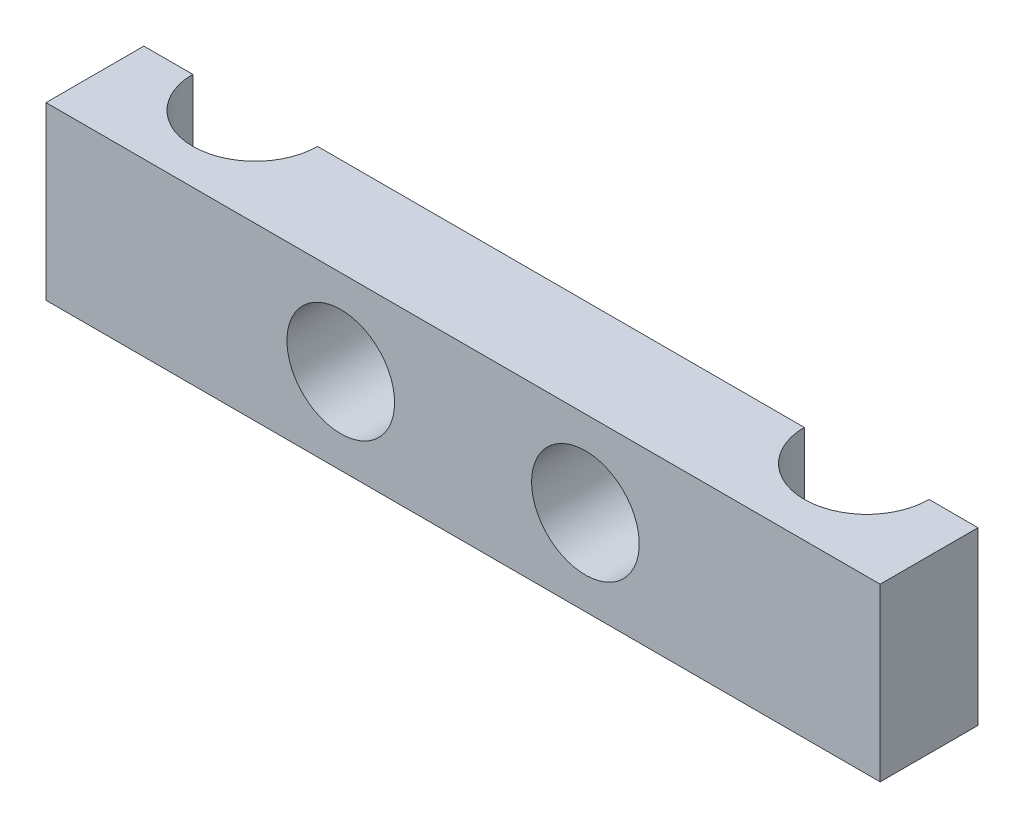
from build123d import *

# Parameters (mm, degrees)
BOSS_EXTRUDE1_DEPTH = 7
SKETCH2_R           = 2.2
CUT_EXTRUDE1_DEPTH  = 4


with BuildPart() as part:
    # Sketch1 → Boss-Extrude1 (new body)
    with BuildSketch(Plane(origin=(0, 0, 0), x_dir=(1, 0, 0), z_dir=(0, 1, 0))):
        with BuildLine():
            Line((0, 0), (-17.05, 0))
            Line((-17.05, 0), (-17.05, 4))
            Line((-17.05, 4), (-15.05, 4))
            ThreePointArc((-15.05, 4), (-12.5, 1.45), (-9.95, 4))
            Line((-9.95, 4), (0, 4))
            Line((0, 4), (0, 0))
        make_face()
    extrude(amount=BOSS_EXTRUDE1_DEPTH)

    # Sketch2 → Cut-Extrude1 (cut)
    with BuildSketch(Plane.XY):
        with Locations((-5, 3.5)):
            Circle(SKETCH2_R)
    extrude(amount=-CUT_EXTRUDE1_DEPTH, mode=Mode.SUBTRACT)

    # Mirror1: part across plane


with BuildPart() as part_1:
    add(part.part)
    add(part.part.mirror(Plane(origin=(0, 0, 0), x_dir=(0, 0, 1), z_dir=(1, 0, 0))))


solid = part_1.part
